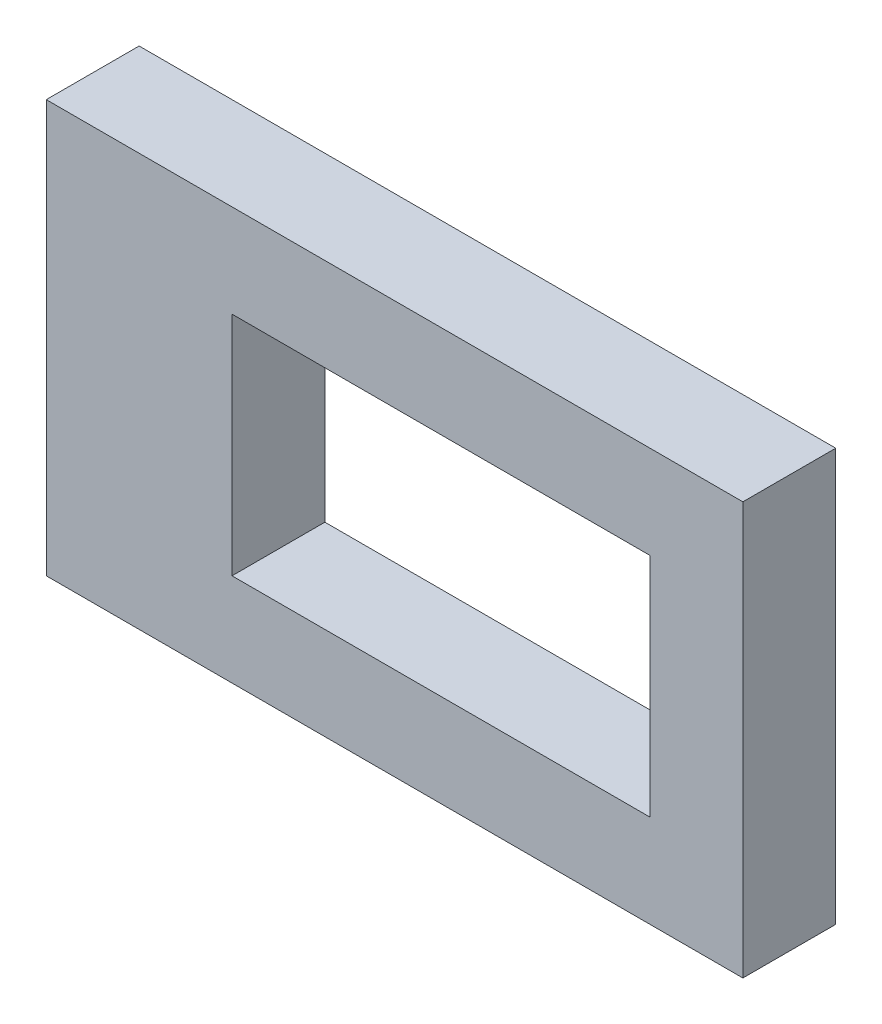
from build123d import *

# Parameters (mm, degrees)
SKETCH1_W           = 37.5
SKETCH1_H           = 22.2
SKETCH1_W_2         = 22.5
SKETCH1_H_2         = 12.2
BOSS_EXTRUDE1_DEPTH = 5


with BuildPart() as part:
    # Sketch1 → Boss-Extrude1 (new body)
    with BuildSketch(Plane.XY):
        with Locations((-13.75, 6.1)):
            Rectangle(SKETCH1_W, SKETCH1_H)
        with Locations((-11.25, 6.1)):
            Rectangle(SKETCH1_W_2, SKETCH1_H_2, mode=Mode.SUBTRACT)
    extrude(amount=BOSS_EXTRUDE1_DEPTH)


solid = part.part
